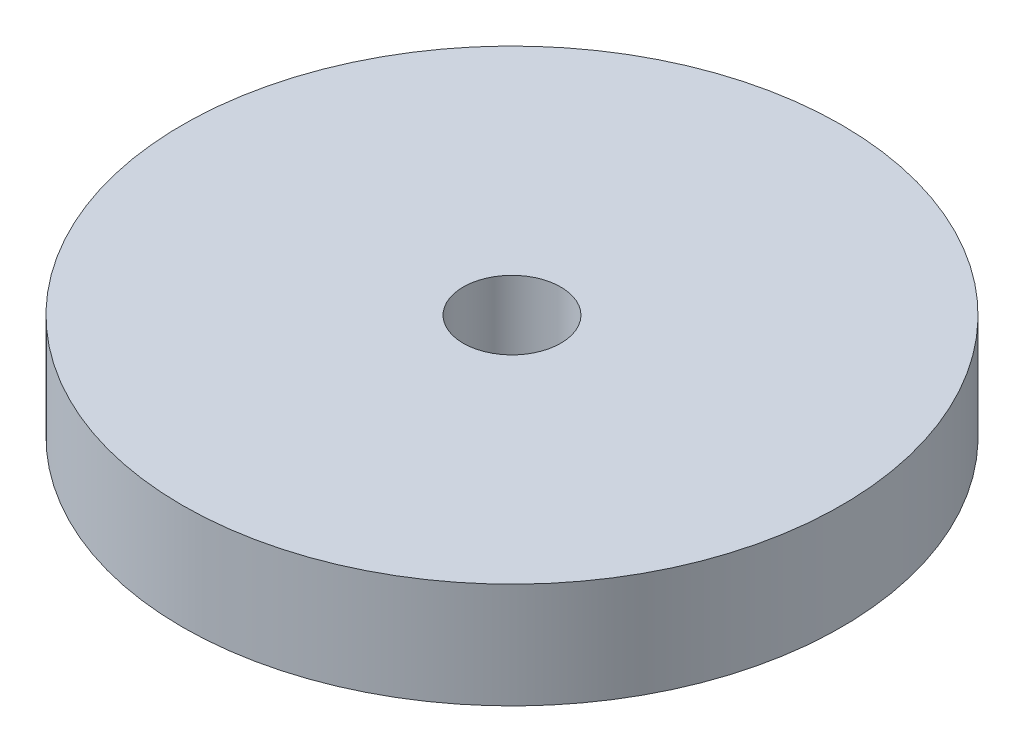
from build123d import *

# Parameters (mm, degrees)
SKETCH1_R           = 12.5
SKETCH1_R_2         = 1.85
BOSS_EXTRUDE1_DEPTH = 2


with BuildPart() as part:
    # Sketch1 → Boss-Extrude1 (new body, symmetric)
    with BuildSketch(Plane(origin=(0, 0, 0), x_dir=(1, 0, 0), z_dir=(0, 1, 0))):
        Circle(SKETCH1_R)
        Circle(SKETCH1_R_2, mode=Mode.SUBTRACT)
    extrude(amount=BOSS_EXTRUDE1_DEPTH, both=True)


solid = part.part
